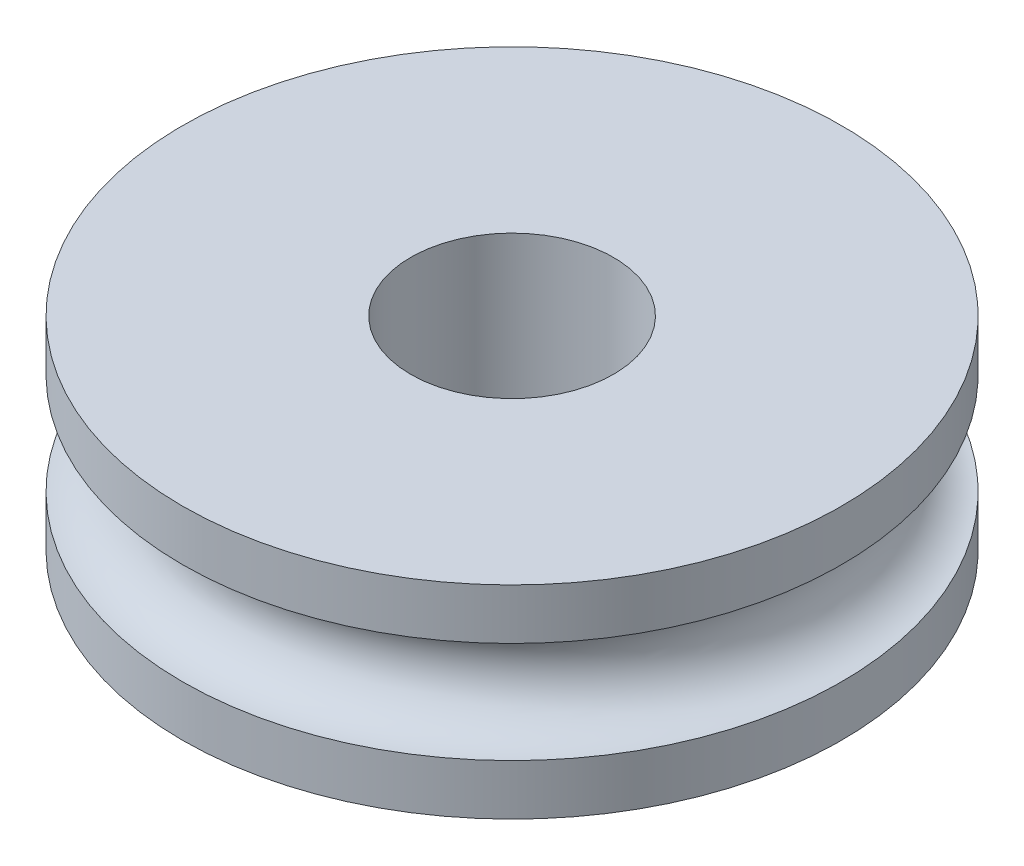
from build123d import *


with BuildPart() as part:
    # Sketch1 → Revolve1 (revolve)
    with BuildSketch(Plane(origin=(0, 0, -44.43), x_dir=(-1, 0, 0), z_dir=(0, 0, -1))):
        with BuildLine():
            Line((-81, 54.526431985), (-81, 53.526431985))
            ThreePointArc((-81, 53.526431985), (-80, 52.526431985), (-81, 51.526431985))
            Line((-81, 51.526431985), (-81, 50.526431985))
            Line((-81, 50.526431985), (-76.5, 50.526431985))
            Line((-76.5, 50.526431985), (-76.5, 54.526431985))
            Line((-76.5, 54.526431985), (-81, 54.526431985))
        make_face()
    revolve(axis=Axis((74.5, 50.526431985, -44.43), (0, 1, 0)))


solid = part.part
